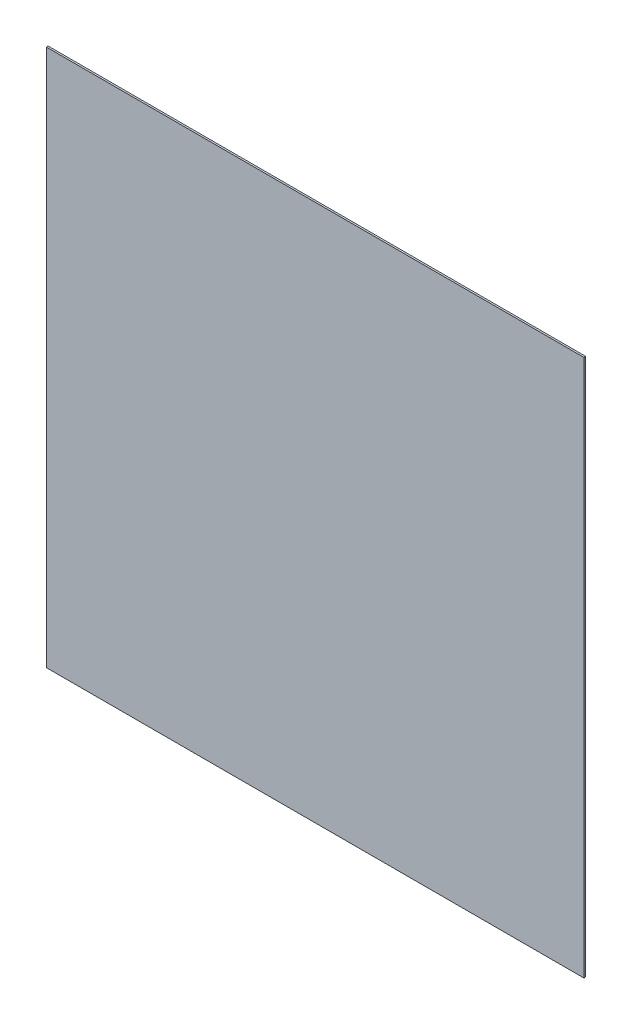
from build123d import *

# Parameters (mm, degrees)
SKETCH_1_W      = 300
SKETCH_1_H      = 300
EXTRUDE_1_DEPTH = 1


with BuildPart() as part:
    # 草图1 → 凸台-拉伸1 (new body)
    with BuildSketch(Plane.XY):
        with Locations((150, 150)):
            Rectangle(SKETCH_1_W, SKETCH_1_H)
    extrude(amount=EXTRUDE_1_DEPTH)


solid = part.part
